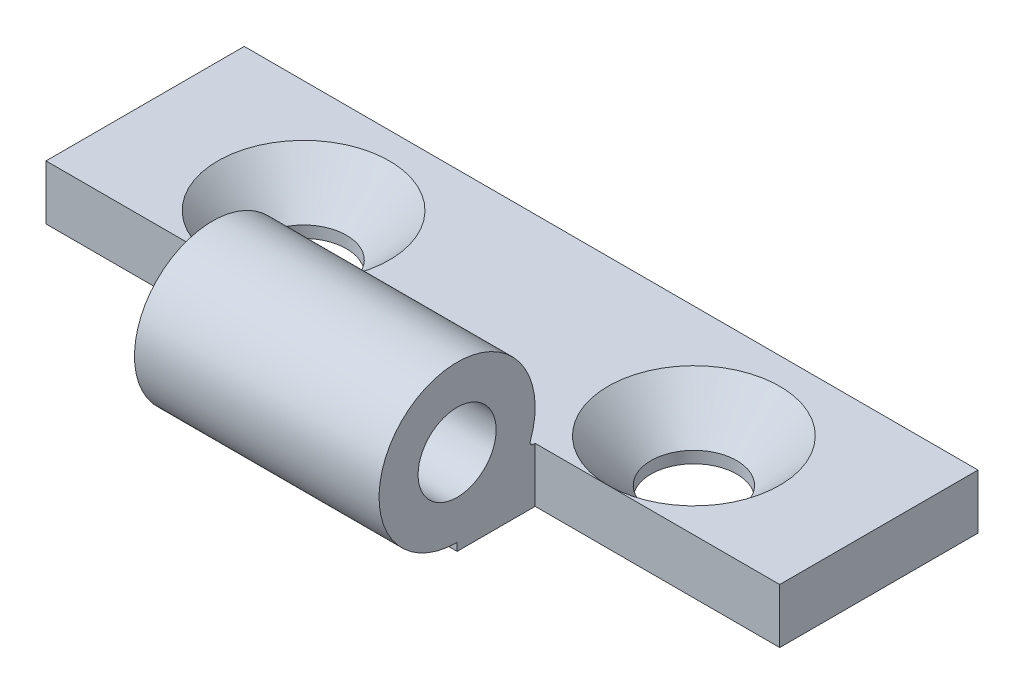
from build123d import *

# Parameters (mm, degrees)
SKETCH1_R                = 2.5
BOSS_EXTRUDE1_DEPTH      = 36
BOSS_EXTRUDE1_DEPTH_BACK = 11
CSK1_AT_2_COUNT          = 2
CSK1_AT_2_PITCH          = 25
SKETCH4_W                = 15.666666667
SKETCH4_H                = 10
CUT_EXTRUDE1_DEPTH       = 11.5


with BuildPart() as part:
    # Sketch1 → Boss-Extrude1 (new body, two sides)
    with BuildSketch(Plane(origin=(0, 0, 0), x_dir=(0, 0, -1), z_dir=(1, 0, 0))) as boss_extrude1_sk:
        with BuildLine():
            Line((-10.5, 0.5), (-10.5, 0))
            Line((-10.5, 0), (7.2, 0))
            Line((7.2, 0), (7.2, 3.5))
            Line((7.2, 3.5), (-5.621475633, 3.5))
            ThreePointArc((-5.621475633, 3.5), (-5.785558164, 3.585645625), (-5.809111186, 3.769230769))
            ThreePointArc((-5.809111186, 3.769230769), (-13.358859374, 9.602063271), (-10.5, 0.5))
        make_face()
        with Locations((-10.5, 5.5)):
            Circle(SKETCH1_R, mode=Mode.SUBTRACT)
    extrude(amount=BOSS_EXTRUDE1_DEPTH)
    extrude(boss_extrude1_sk.sketch, amount=-BOSS_EXTRUDE1_DEPTH_BACK)

    # Sketch2 → CSK1 (revolve, cut)
    with BuildSketch(Plane(origin=(0, 3.5, 0), x_dir=(0, 0, 1), z_dir=(1, 0, 0))):
        Polygon((0, 0), (0, 3.5), (2.75, 3.5), (2.75, 2.75), (5.5, 0), align=None)
    csk1 = revolve(axis=Axis((0, 9.85, 0), (0, -1, 0)), mode=Mode.SUBTRACT)

    # CSK1 at 2: CSK1 ×2
    with Locations(*[(i * CSK1_AT_2_PITCH, 0, 0) for i in range(1, CSK1_AT_2_COUNT)]):
        add(csk1, mode=Mode.SUBTRACT)

    # Sketch4 → Cut-Extrude1 (cut, through all)
    with BuildSketch(Plane(origin=(0, 0, 0), x_dir=(1, 0, 0), z_dir=(0, 1, 0))):
        with Locations((-3.166666666, -10.5)):
            Rectangle(SKETCH4_W, SKETCH4_H)
        with Locations((28.166666666, -10.5)):
            Rectangle(SKETCH4_W, SKETCH4_H)
    extrude(amount=CUT_EXTRUDE1_DEPTH, mode=Mode.SUBTRACT)


solid = part.part
